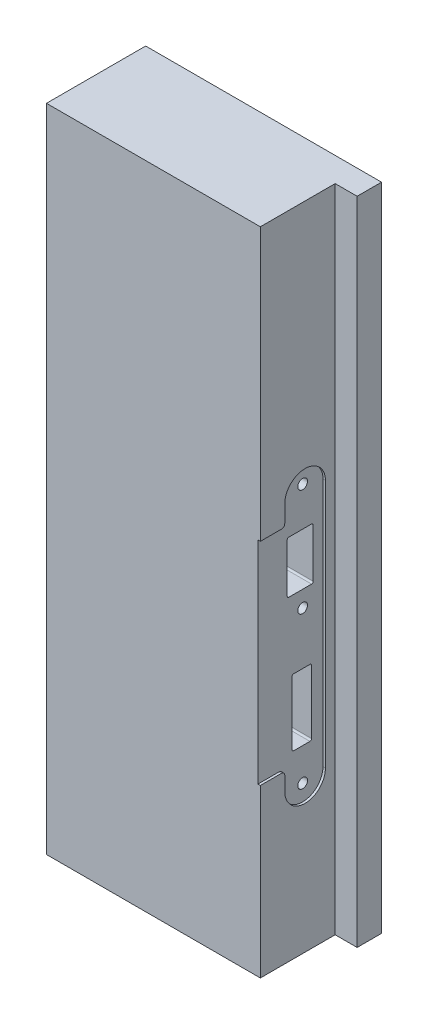
from build123d import *

# Parameters (mm, degrees)
EXTRUSION1_DEPTH        = 1.5
ESQUISSE3_W             = 46
ESQUISSE3_H             = 400
EXTRUSION2_DEPTH        = 130
ESQUISSE4_W             = 15
ESQUISSE4_H             = 400
EXTRUSION3_DEPTH        = 145
ESQUISSE7_R             = 3
ENL_V_MAT_EXTRU_1_DEPTH = 20


with BuildPart() as part:
    # Esquisse2 → Extrusion1 (new body)
    with BuildSketch(Plane.ZY.offset(-405.393457589)):
        with BuildLine():
            Line((-30.551651131, -238.253062947), (-30.551651131, -405.753062947))
            Line((-30.551651131, -405.753062947), (-43.551651131, -405.753062947))
            ThreePointArc((-43.551651131, -405.753062947), (-44.965864693, -405.16727651), (-45.551651131, -403.753062947))
            Line((-45.551651131, -403.753062947), (-45.551651131, -393.253062947))
            ThreePointArc((-45.551651131, -393.253062947), (-58.051651131, -380.753062947), (-70.551651131, -393.253062947))
            Line((-70.551651131, -393.253062947), (-70.551651131, -546.503062947))
            ThreePointArc((-70.551651131, -546.503062947), (-58.051651131, -559.003062947), (-45.551651131, -546.503062947))
            Line((-45.551651131, -546.503062947), (-45.551651131, -537.753062947))
            ThreePointArc((-45.551651131, -537.753062947), (-44.965864693, -536.338849385), (-43.551651131, -535.753062947))
            Line((-43.551651131, -535.753062947), (-30.551651131, -535.753062947))
            Line((-30.551651131, -535.753062947), (-30.551651131, -638.253062947))
            Line((-30.551651131, -638.253062947), (-76.551651131, -638.253062947))
            Line((-76.551651131, -638.253062947), (-76.551651131, -238.253062947))
            Line((-76.551651131, -238.253062947), (-30.551651131, -238.253062947))
        make_face()
    extrude(amount=-EXTRUSION1_DEPTH)

    # Esquisse3 → Extrusion2 (add)
    with BuildSketch(Plane.ZY.offset(-405.393457589)):
        with Locations((-53.551651131, -438.253062947)):
            Rectangle(ESQUISSE3_W, ESQUISSE3_H)
    extrude(amount=EXTRUSION2_DEPTH)

    # Esquisse4 → Extrusion3 (add)
    with BuildSketch(Plane.ZY.offset(-275.393457589)):
        with Locations((-84.051651131, -438.253062947)):
            Rectangle(ESQUISSE4_W, ESQUISSE4_H)
    extrude(amount=-EXTRUSION3_DEPTH)

    # Esquisse7 → Enlèv. mat.-Extru.1 (cut)
    with BuildSketch(Plane(origin=(405.393457589, 0, 0), x_dir=(0, 0, -1), z_dir=(1, 0, 0))):
        with Locations((58.051651131, -389.753062947)):
            Circle(ESQUISSE7_R)
        with Locations((58.051651131, -455.753062947)):
            Circle(ESQUISSE7_R)
        with Locations((58.051651131, -549.003062947)):
            Circle(ESQUISSE7_R)
        with BuildLine():
            Line((48.551651131, -414.753062947), (48.551651131, -444.753062947))
            ThreePointArc((48.551651131, -444.753062947), (48.84454435, -445.460169728), (49.551651131, -445.753062947))
            Line((49.551651131, -445.753062947), (63.551651131, -445.753062947))
            ThreePointArc((63.551651131, -445.753062947), (64.258757912, -445.460169728), (64.551651131, -444.753062947))
            Line((64.551651131, -444.753062947), (64.551651131, -414.753062947))
            ThreePointArc((64.551651131, -414.753062947), (64.258757912, -414.045956166), (63.551651131, -413.753062947))
            Line((63.551651131, -413.753062947), (49.551651131, -413.753062947))
            ThreePointArc((49.551651131, -413.753062947), (48.84454435, -414.045956166), (48.551651131, -414.753062947))
        make_face()
        with BuildLine():
            Line((63.551651131, -528.003062947), (63.551651131, -489.003062947))
            ThreePointArc((63.551651131, -489.003062947), (63.258757912, -488.295956166), (62.551651131, -488.003062947))
            Line((62.551651131, -488.003062947), (52.551651131, -488.003062947))
            ThreePointArc((52.551651131, -488.003062947), (51.84454435, -488.295956166), (51.551651131, -489.003062947))
            Line((51.551651131, -489.003062947), (51.551651131, -528.003062947))
            ThreePointArc((51.551651131, -528.003062947), (51.84454435, -528.710169728), (52.551651131, -529.003062947))
            Line((52.551651131, -529.003062947), (62.551651131, -529.003062947))
            ThreePointArc((62.551651131, -529.003062947), (63.258757912, -528.710169728), (63.551651131, -528.003062947))
        make_face()
    extrude(amount=-ENL_V_MAT_EXTRU_1_DEPTH, mode=Mode.SUBTRACT)


solid = part.part
